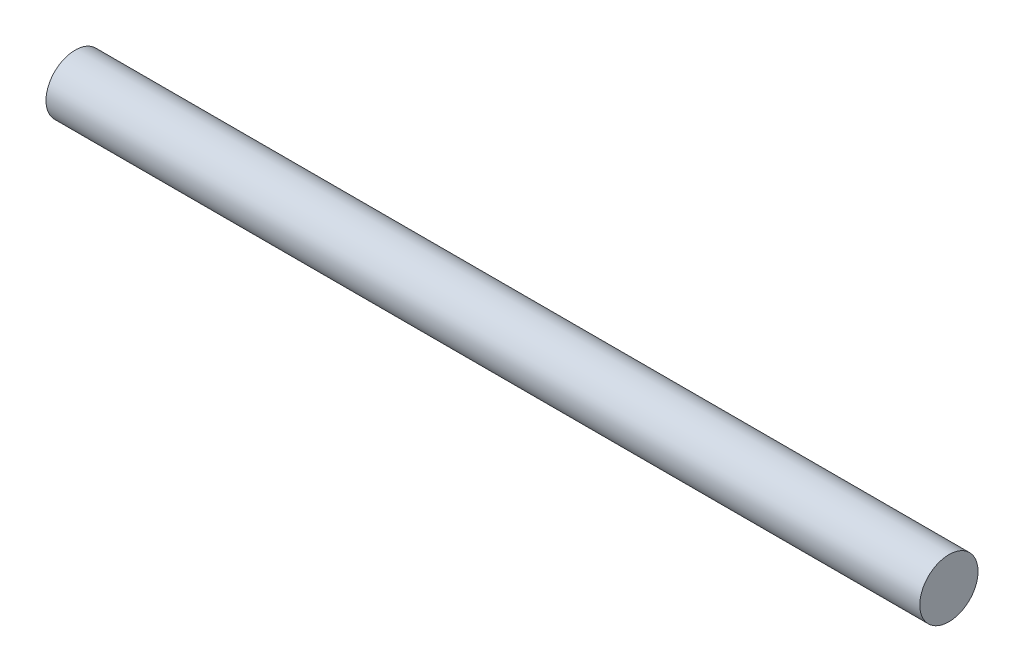
from build123d import *

# Parameters (mm, degrees)
SKETCH1_W = 45
SKETCH1_H = 1.5


with BuildPart() as part:
    # Sketch1 → Revolve1 (revolve)
    with BuildSketch(Plane.XY):
        with Locations((22.5, 0.75)):
            Rectangle(SKETCH1_W, SKETCH1_H)
    revolve(axis=Axis((0, 0, 0), (1, 0, 0)))


solid = part.part
